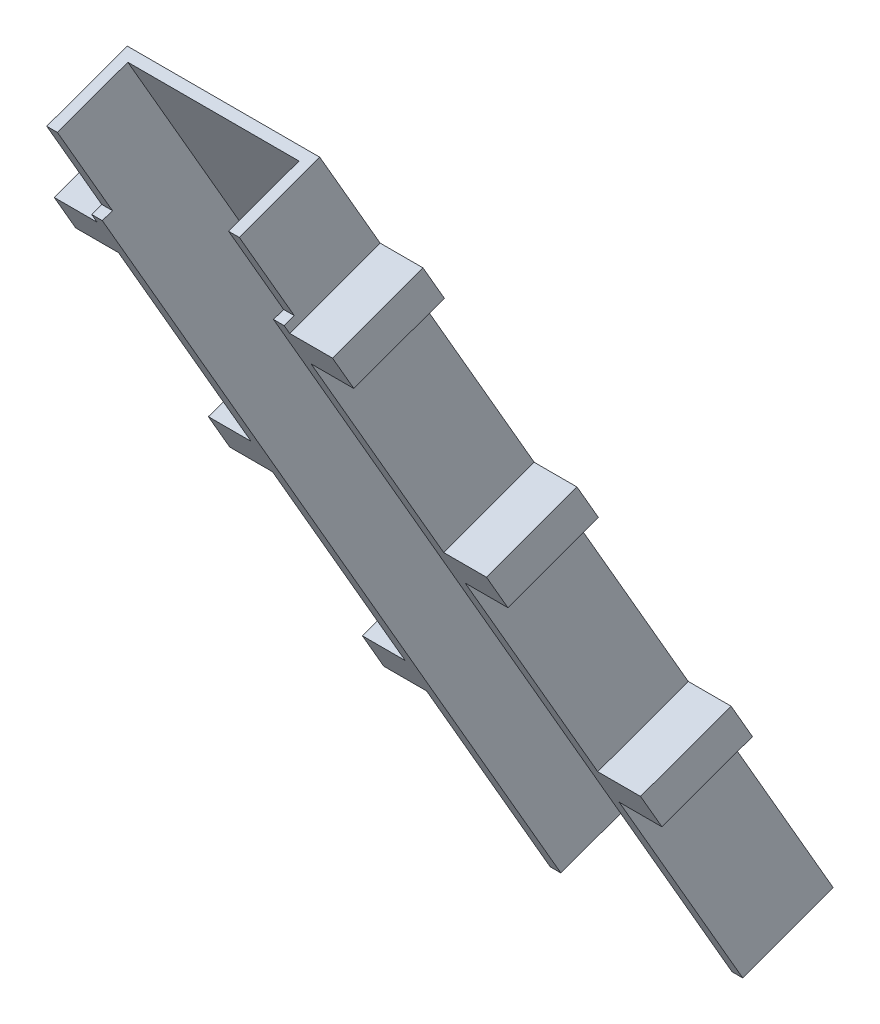
from build123d import *

# Parameters (mm, degrees)
BOSS_EXTRUDE1_DEPTH   = 28.575
SKETCH2_W             = 25.4
SKETCH2_H             = 14.2875
CUT_EXTRUDE2_DEPTH    = 159.114345309
CUT_EXTRUDE3_DEPTH    = 29.575
CUT_EXTRUDE4_DEPTH    = 25.4
SKETCH6_W             = 1.5875
SKETCH6_H             = 82.55
BOSS_EXTRUDE2_DEPTH   = 1.5875
CUT_EXTRUDE5_DEPTH    = 29.575
CUT_EXTRUDE6_DEPTH    = 29.575
BOSS_EXTRUDE3_DEPTH   = 6.35
BOSS_EXTRUDE3_2_DEPTH = 6.35
BOSS_EXTRUDE3_3_DEPTH = 6.35


with BuildPart() as part:
    # Sketch1 → Boss-Extrude1 (new body)
    with BuildSketch(Plane(origin=(0, 0, 0), x_dir=(0, 0, -1), z_dir=(1, 0, 0))):
        Polygon((0, 0), (-76.2, 131.982271537), (-59.79061761, 137.95479829), (16.40938239, 5.972526753), align=None)
    extrude(amount=BOSS_EXTRUDE1_DEPTH)

    # Sketch2 → Cut-Extrude2 (cut, through all, along a direction that is not the sketch's normal)
    with BuildSketch(Plane(origin=(0, 141.033486548, 51.331991138), x_dir=(1, 0, 0), z_dir=(0, 0.939692621, 0.342020143))):
        with Locations((14.2875, -17.732732276)):
            Rectangle(SKETCH2_W, SKETCH2_H)
    extrude(amount=-CUT_EXTRUDE2_DEPTH, dir=(0, 0.866025404, 0.5), mode=Mode.SUBTRACT)

    # Sketch3 → Cut-Extrude3 (cut, through all)
    with BuildSketch(Plane(origin=(28.575, 0, 0), x_dir=(0, 0, -1), z_dir=(1, 0, 0))):
        Polygon((-76.2, 131.982271537), (-74.708237965, 132.525228514), (-33.433237965, 61.034831432), (-34.925, 60.491874454), align=None)
    extrude(amount=-CUT_EXTRUDE3_DEPTH, mode=Mode.SUBTRACT)

    # Sketch4 → Cut-Extrude4 (cut)
    with BuildSketch(Plane(origin=(1.5875, 0, 0), x_dir=(0, 0, -1), z_dir=(1, 0, 0))):
        Polygon((-43.162002392, 69.198234075), (-23.704473537, 52.871428789), (-24.724898867, 51.655333235), (-44.182427722, 67.982138521), align=None)
    extrude(amount=CUT_EXTRUDE4_DEPTH, mode=Mode.SUBTRACT)

    # Sketch6 → Boss-Extrude2 (add, along a direction that is not the sketch's normal)
    with BuildSketch(Plane(origin=(0, 0.781691154, -1.353928794), x_dir=(1, 0, 0), z_dir=(0, -0.5, 0.866025404))):
        with Locations((27.78125, 110.849333518)):
            Rectangle(SKETCH6_W, SKETCH6_H)
        with Locations((0.79375, 110.849333518)):
            Rectangle(SKETCH6_W, SKETCH6_H)
    extrude(amount=BOSS_EXTRUDE2_DEPTH, dir=(0, -0.342020143, 0.939692621))

    # Sketch7 → Cut-Extrude5 (cut, through all)
    with BuildSketch(Plane(origin=(28.575, 0, 0), x_dir=(0, 0, -1), z_dir=(1, 0, 0))):
        Polygon((-76.2, 131.982271537), (-71.724713894, 133.611142469), (-63.568463887, 119.484103058), (-68.043749993, 117.855232125), align=None)
    extrude(amount=-CUT_EXTRUDE5_DEPTH, mode=Mode.SUBTRACT)

    # Sketch8 → Cut-Extrude6 (cut, through all)
    with BuildSketch(Plane(origin=(28.575, 0, 0), x_dir=(0, 0, -1), z_dir=(1, 0, 0))):
        Polygon((-68.043749993, 117.855232125), (-65.060225922, 118.94114608), (2.983524071, 1.085913955), (0, 0), align=None)
    extrude(amount=-CUT_EXTRUDE6_DEPTH, mode=Mode.SUBTRACT)


with BuildPart() as body_2:
    # Sketch9 → Boss-Extrude3 (new body)
    with BuildSketch(Plane(origin=(28.575, 0, 0), x_dir=(0, 0, -1), z_dir=(1, 0, 0))):
        Polygon((-64.254231049, 117.545122009), (-50.828372729, 122.431734807), (-47.653372729, 116.932473493), (-61.079231049, 112.045860695), align=None)
    extrude(amount=BOSS_EXTRUDE3_DEPTH)


with BuildPart() as body_3:
    # Sketch9 → Boss-Extrude3 2 (new body)
    with BuildSketch(Plane(origin=(28.575, 0, 0), x_dir=(0, 0, -1), z_dir=(1, 0, 0))):
        Polygon((-41.394231049, 77.950440548), (-27.968372729, 82.837053346), (-24.793372729, 77.337792032), (-38.219231049, 72.451179234), align=None)
    extrude(amount=BOSS_EXTRUDE3_2_DEPTH)


with BuildPart() as body_4:
    # Sketch9 → Boss-Extrude3 3 (new body)
    with BuildSketch(Plane(origin=(28.575, 0, 0), x_dir=(0, 0, -1), z_dir=(1, 0, 0))):
        Polygon((-18.534231049, 38.355759087), (-5.108372729, 43.242371885), (-1.933372729, 37.743110571), (-15.359231049, 32.856497773), align=None)
    extrude(amount=BOSS_EXTRUDE3_3_DEPTH)


with BuildPart() as body_5:
    # Mirror1: mirrored copy
    add(body_2.part.mirror(Plane.ZY.offset(-14.2875)))


with BuildPart() as body_6:
    # Mirror1 2: mirrored copy
    add(body_3.part.mirror(Plane.ZY.offset(-14.2875)))


with BuildPart() as body_7:
    # Mirror1 3: mirrored copy
    add(body_4.part.mirror(Plane.ZY.offset(-14.2875)))


with BuildPart() as part_1:
    add(part.part)

    # Combine1: union body 2, body 3, body 4, body 7, body 6, body 5
    add(body_2.part)
    add(body_3.part)
    add(body_4.part)
    add(body_7.part)
    add(body_6.part)
    add(body_5.part)


solid = part_1.part
